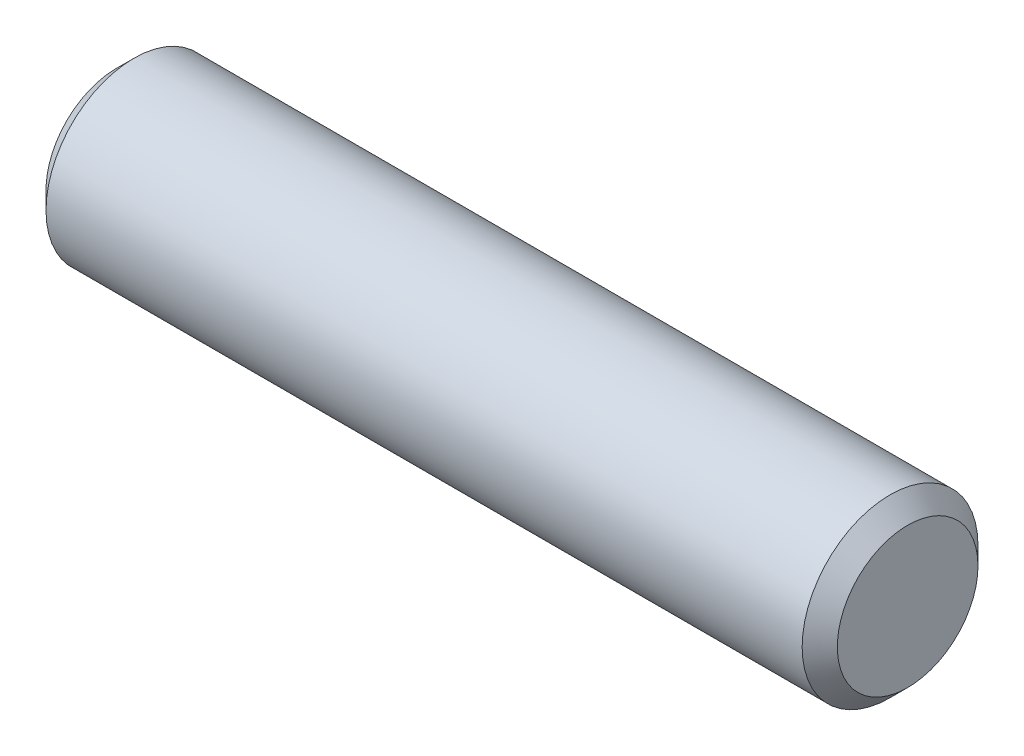
from build123d import *

# Parameters (mm, degrees)
SKETCH2_R           = 6.35
EXTRUDE1_DEPTH      = 28.575
EXTRUDE1_DEPTH_BACK = 28.575
CHAMFER1_SIZE       = 1.27


with BuildPart() as part:
    # Sketch2 → Extrude1 (new body, two sides)
    with BuildSketch(Plane(origin=(0, 0, 0), x_dir=(0, 0, -1), z_dir=(1, 0, 0))) as extrude1_sk:
        Circle(SKETCH2_R)
    extrude(amount=EXTRUDE1_DEPTH)
    extrude(extrude1_sk.sketch, amount=-EXTRUDE1_DEPTH_BACK)

    # Chamfer1
    chamfer1_edges = [part.edges().sort_by_distance(p)[0] for p in [
        (-28.575, 0, 6.35),
        (28.575, 0, 6.35),
    ]]
    chamfer(chamfer1_edges, length=CHAMFER1_SIZE)


solid = part.part
